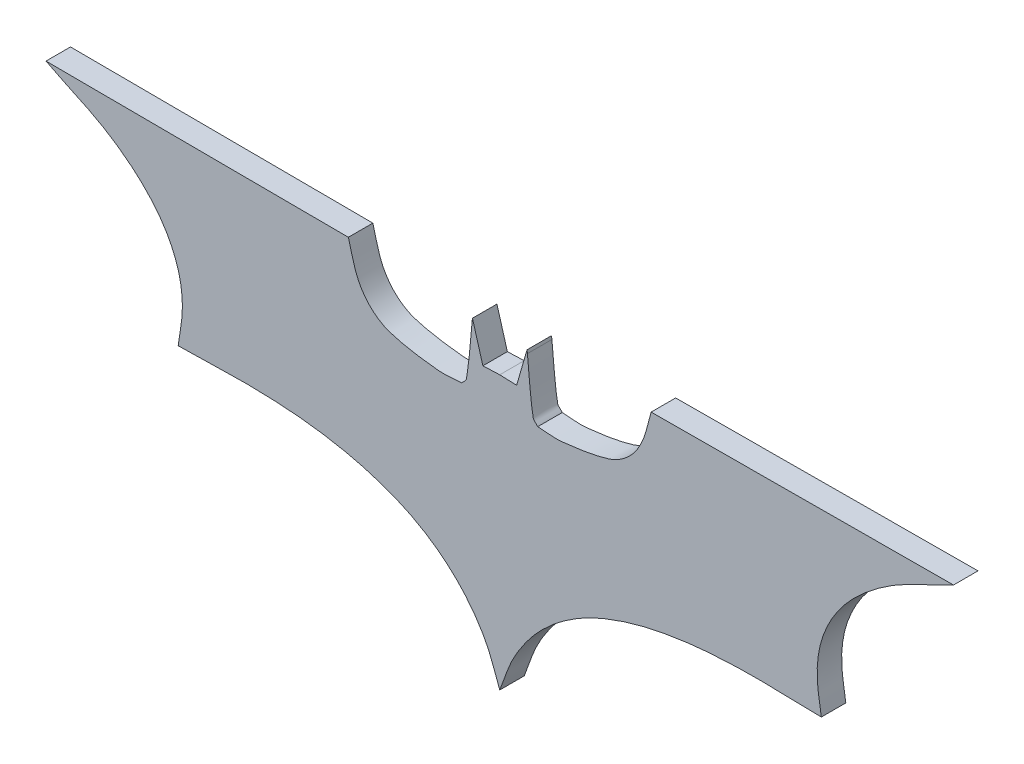
from build123d import *

# Parameters (mm, degrees)
BOSS_EXTRUDE4_DEPTH = 2.7


with BuildPart() as part:
    # Sketch1 → Boss-Extrude4 (new body)
    with BuildSketch(Plane.XY):
        with BuildLine():
            Line((1.8602352, 12.5049144), (0, 12.576461908))
            Line((0, 12.576461908), (-1.8602352, 12.5049144))
            Line((-1.8602352, 12.5049144), (-2.8936992, 16.0703652))
            Line((-2.8936992, 16.0703652), (-3.010675932, 16.473934926))
            Line((-3.010675932, 16.473934926), (-3.0487188, 16.1220384))
            add(Edge.make_bspline(
                [(-4.1855292, 9.7145616), (-4.0132852, 9.9384788), (-3.718147674, 10.108155981), (-3.6687972, 10.3863132), (-3.332857498, 12.279791523), (-3.2554116, 14.21013), (-3.0487188, 16.1220384)],
                knots=[0, 0, 0, 0, 1, 1, 1, 2, 2, 2, 2], degree=3))
            add(Edge.make_bspline(
                [(-16.6904436, 17.3621952), (-16.3459556, 16.2253848), (-16.151559223, 15.0317644), (-15.6569796, 13.951764), (-15.296825936, 13.165306), (-14.792006047, 12.422095903), (-14.1584568, 11.8331628), (-13.541839206, 11.25996898), (-12.793933496, 10.78532785), (-11.9881824, 10.5413328), (-10.313174622, 10.034112135), (-8.561240653, 9.795626141), (-6.8208624, 9.6112152), (-5.946636812, 9.518582025), (-5.0639736, 9.6801128), (-4.1855292, 9.7145616)],
                knots=[0, 0, 0, 0, 1, 1, 1, 2, 2, 2, 3, 3, 3, 4, 4, 4, 5, 5, 5, 5], degree=3))
            Line((-16.6904436, 17.3621952), (-50.0196576, 17.5172148))
            add(Edge.make_bspline(
                [(-35.4478152, -2.3769672), (-35.2927956, -1.0679128), (-34.973602445, 0.232026548), (-34.9827564, 1.550196), (-34.990977427, 2.734023911), (-35.145413711, 3.934306736), (-35.4994884, 5.0639736), (-35.877348535, 6.269527364), (-36.44648751, 7.427058277), (-37.1530308, 8.4744048), (-37.924187745, 9.617531565), (-38.865562426, 10.653687595), (-39.8917104, 11.5747968), (-41.065925319, 12.628816491), (-42.356636193, 13.563181137), (-43.7155272, 14.3651496), (-45.738857215, 15.559246002), (-47.95106939, 16.40335961), (-50.0196576, 17.5172148)],
                knots=[0, 0, 0, 0, 1, 1, 1, 2, 2, 2, 3, 3, 3, 4, 4, 4, 5, 5, 5, 6, 6, 6, 6], degree=3))
            add(Edge.make_bspline(
                [(0, -17.5172148), (-0.516732, -16.2253848), (-0.893173812, -14.868166218), (-1.550196, -13.6417248), (-2.193223856, -12.441406135), (-2.979408908, -11.308290357), (-3.87549, -10.2829668), (-4.782047761, -9.245655516), (-5.811157197, -8.304388478), (-6.9242088, -7.492614), (-8.115261393, -6.623951583), (-9.398694557, -5.864372059), (-10.7480256, -5.2706664), (-12.428169619, -4.531403032), (-14.182113438, -3.942154887), (-15.9670188, -3.5137776), (-18.070709225, -3.008891898), (-20.219400833, -2.670022646), (-22.3744956, -2.4803136), (-25.1720997, -2.234045633), (-27.990264816, -2.183073626), (-30.7972272, -2.2736208), (-32.346999794, -2.323613464), (-33.8976192, -2.3425184), (-35.4478152, -2.3769672)],
                knots=[0, 0, 0, 0, 1, 1, 1, 2, 2, 2, 3, 3, 3, 4, 4, 4, 5, 5, 5, 6, 6, 6, 7, 7, 7, 8, 8, 8, 8], degree=3))
            add(Edge.make_bspline(
                [(0, -17.5172148), (0.516732, -16.2253848), (0.893173812, -14.868166218), (1.550196, -13.6417248), (2.193223856, -12.441406135), (2.979408908, -11.308290357), (3.87549, -10.2829668), (4.782047761, -9.245655516), (5.811157197, -8.304388478), (6.9242088, -7.492614), (8.115261393, -6.623951583), (9.398694557, -5.864372059), (10.7480256, -5.2706664), (12.428169619, -4.531403032), (14.182113438, -3.942154887), (15.9670188, -3.5137776), (18.070709225, -3.008891898), (20.219400833, -2.670022646), (22.3744956, -2.4803136), (25.1720997, -2.234045633), (27.990264816, -2.183073626), (30.7972272, -2.2736208), (32.346999794, -2.323613464), (33.8976192, -2.3425184), (35.4478152, -2.3769672)],
                knots=[0, 0, 0, 0, 1, 1, 1, 2, 2, 2, 3, 3, 3, 4, 4, 4, 5, 5, 5, 6, 6, 6, 7, 7, 7, 8, 8, 8, 8], degree=3))
            add(Edge.make_bspline(
                [(35.4478152, -2.3769672), (35.2927956, -1.0679128), (34.973602445, 0.232026548), (34.9827564, 1.550196), (34.990977427, 2.734023911), (35.145413711, 3.934306736), (35.4994884, 5.0639736), (35.877348535, 6.269527364), (36.44648751, 7.427058277), (37.1530308, 8.4744048), (37.924187745, 9.617531565), (38.865562426, 10.653687595), (39.8917104, 11.5747968), (41.065925319, 12.628816491), (42.356636193, 13.563181137), (43.7155272, 14.3651496), (45.738857215, 15.559246002), (47.95106939, 16.40335961), (50.0196576, 17.5172148)],
                knots=[0, 0, 0, 0, 1, 1, 1, 2, 2, 2, 3, 3, 3, 4, 4, 4, 5, 5, 5, 6, 6, 6, 6], degree=3))
            Line((50.0196576, 17.5172148), (16.6904436, 17.3621952))
            add(Edge.make_bspline(
                [(16.6904436, 17.3621952), (16.3459556, 16.2253848), (16.151559223, 15.0317644), (15.6569796, 13.951764), (15.296825936, 13.165306), (14.792006047, 12.422095903), (14.1584568, 11.8331628), (13.541839206, 11.25996898), (12.793933496, 10.78532785), (11.9881824, 10.5413328), (10.313174622, 10.034112135), (8.561240653, 9.795626141), (6.8208624, 9.6112152), (5.946636812, 9.518582025), (5.0639736, 9.6801128), (4.1855292, 9.7145616)],
                knots=[0, 0, 0, 0, 1, 1, 1, 2, 2, 2, 3, 3, 3, 4, 4, 4, 5, 5, 5, 5], degree=3))
            add(Edge.make_bspline(
                [(4.1855292, 9.7145616), (4.0132852, 9.9384788), (3.718147674, 10.108155981), (3.6687972, 10.3863132), (3.332857498, 12.279791523), (3.2554116, 14.21013), (3.0487188, 16.1220384)],
                knots=[0, 0, 0, 0, 1, 1, 1, 2, 2, 2, 2], degree=3))
            Line((3.0487188, 16.1220384), (3.010675932, 16.473934926))
            Line((3.010675932, 16.473934926), (2.8936992, 16.0703652))
            Line((2.8936992, 16.0703652), (1.8602352, 12.5049144))
        make_face()
    extrude(amount=BOSS_EXTRUDE4_DEPTH)


solid = part.part
